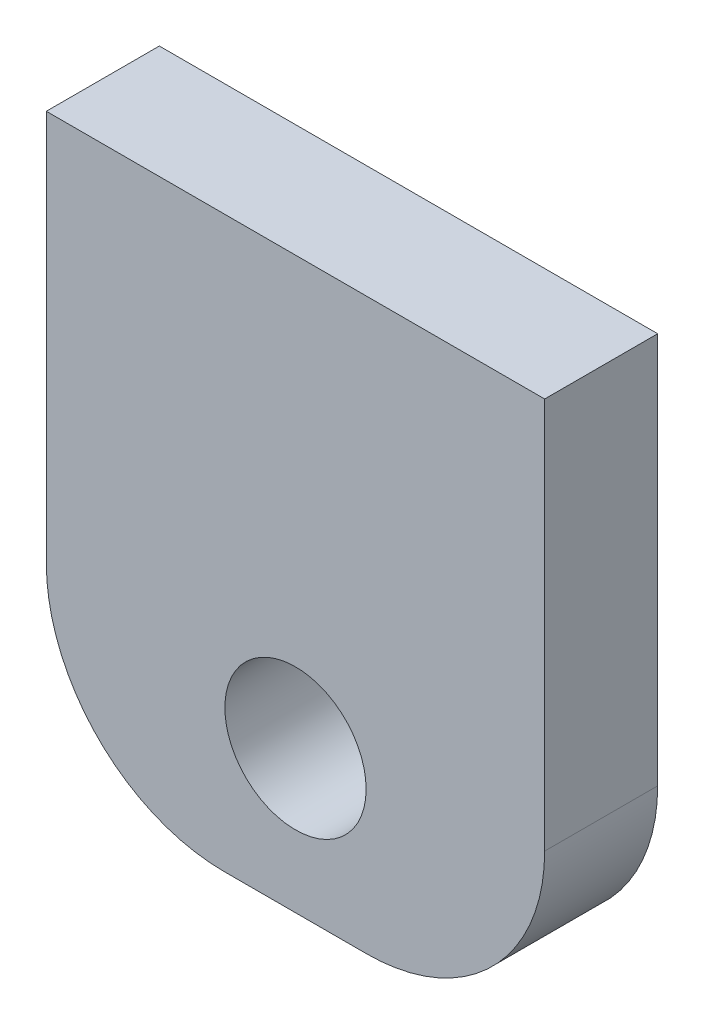
from build123d import *

# Parameters (mm, degrees)
CROQUIS1_W              = 28
CROQUIS1_H              = 32
CROQUIS1_R              = 3.96875
SALIENTE_EXTRUIR1_DEPTH = 6.35
REDONDEO1_R             = 10


with BuildPart() as part:
    # Croquis1 → Saliente-Extruir1 (new body)
    with BuildSketch(Plane.XY):
        with Locations((14, -16)):
            Rectangle(CROQUIS1_W, CROQUIS1_H)
        with Locations((14, -24)):
            Circle(CROQUIS1_R, mode=Mode.SUBTRACT)
    extrude(amount=SALIENTE_EXTRUIR1_DEPTH)

    # Redondeo1
    redondeo1_edges = [part.edges().sort_by_distance(p)[0] for p in [
        (28, -32, 3.175),
        (0, -32, 3.175),
    ]]
    fillet(redondeo1_edges, radius=REDONDEO1_R)


solid = part.part
